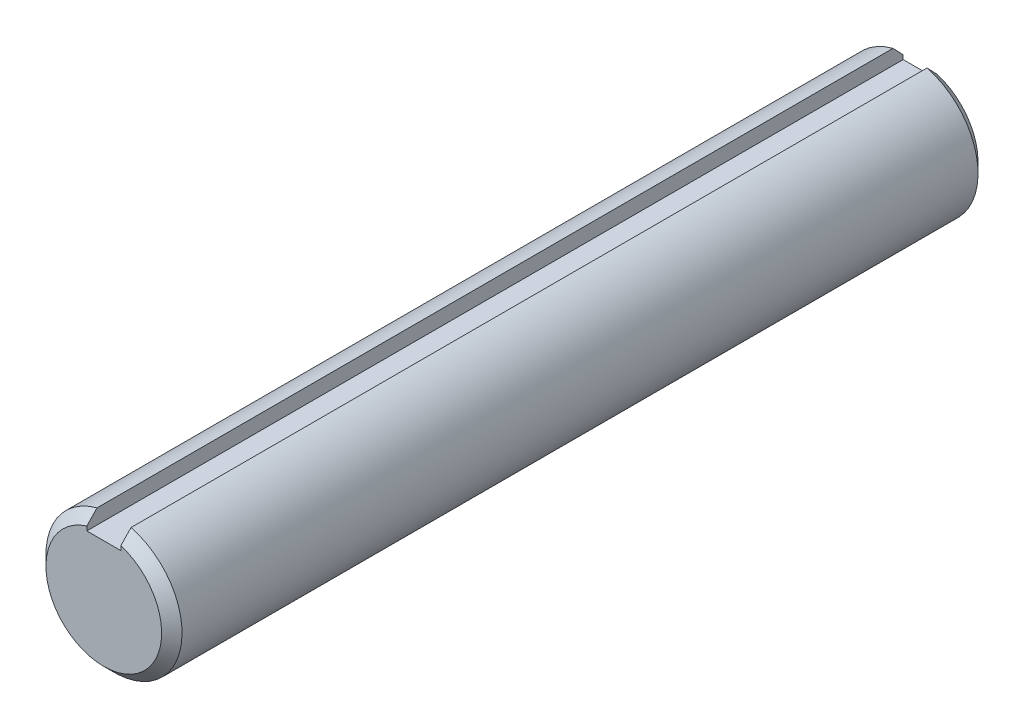
from build123d import *

# Parameters (mm, degrees)
SKETCH1_R           = 6.35
EXTRUDE1_DEPTH      = 38.1
CHAMFER1_SIZE       = 0.9525
SKETCH3_W           = 3.175
SKETCH3_H           = 1.5875
EXTRUDE2_DEPTH      = 39.1
EXTRUDE2_DEPTH_BACK = 39.1


with BuildPart() as part:
    # Sketch1 → Extrude1 (new body, symmetric)
    with BuildSketch(Plane.XY):
        Circle(SKETCH1_R)
    extrude(amount=EXTRUDE1_DEPTH, both=True)

    # Chamfer1
    chamfer1_edges = [part.edges().sort_by_distance(p)[0] for p in [
        (-6.35, 0, -38.1),
        (-6.35, 0, 38.1),
    ]]
    chamfer(chamfer1_edges, length=CHAMFER1_SIZE)

    # Sketch3 → Extrude2 (cut, two sides)
    with BuildSketch(Plane.XY) as extrude2_sk:
        with Locations((0, 5.55625)):
            Rectangle(SKETCH3_W, SKETCH3_H)
    extrude(amount=EXTRUDE2_DEPTH, mode=Mode.SUBTRACT)
    extrude(extrude2_sk.sketch, amount=-EXTRUDE2_DEPTH_BACK, mode=Mode.SUBTRACT)


solid = part.part
